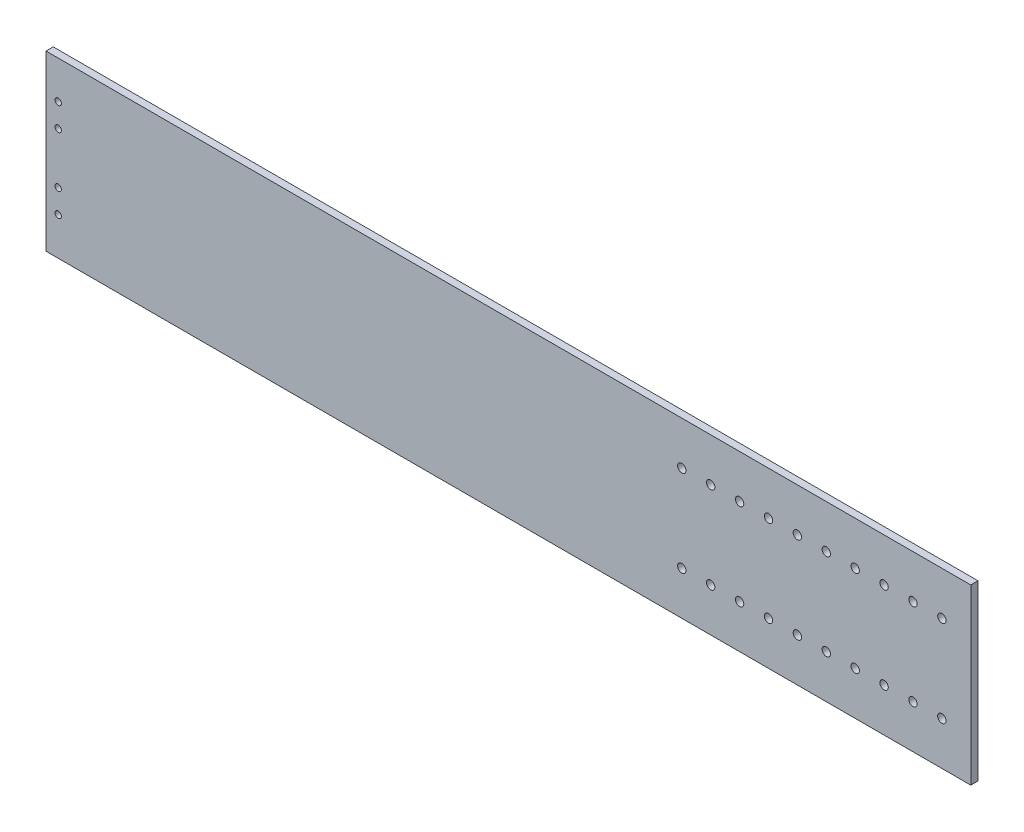
from build123d import *

# Parameters (mm, degrees)
SKETCH1_W             = 406.4
SKETCH1_H             = 76.2
BASIC_PLANK_DEPTH     = 3.175
SKETCH5_R             = 1.397
BRACKET_HOLES_DEPTH   = 4.175
SKETCH6_R             = 1.8415
PLACEMENT_HOLES_DEPTH = 4.175


with BuildPart() as part:
    # Sketch1 → basic_plank (new body)
    with BuildSketch(Plane.XY):
        with Locations((203.2, 38.1)):
            Rectangle(SKETCH1_W, SKETCH1_H)
    extrude(amount=BASIC_PLANK_DEPTH)

    # Sketch5 → bracket holes (cut, through all)
    with BuildSketch(Plane.XY.offset(3.175)):
        with Locations((5.3594, 59.5884)):
            Circle(SKETCH5_R)
        with Locations((5.3594, 16.6116)):
            Circle(SKETCH5_R)
        with Locations((5.3594, 49.3014)):
            Circle(SKETCH5_R)
        with Locations((5.3594, 26.8986)):
            Circle(SKETCH5_R)
    extrude(amount=-BRACKET_HOLES_DEPTH, mode=Mode.SUBTRACT)

    # Sketch6 → placement holes (cut, through all)
    with BuildSketch(Plane.XY.offset(3.175)):
        with Locations((279.4, 57.15)):
            Circle(SKETCH6_R)
        with Locations((292.1, 57.15)):
            Circle(SKETCH6_R)
        with Locations((304.8, 57.15)):
            Circle(SKETCH6_R)
        with Locations((317.5, 57.15)):
            Circle(SKETCH6_R)
        with Locations((330.2, 57.15)):
            Circle(SKETCH6_R)
        with Locations((342.9, 57.15)):
            Circle(SKETCH6_R)
        with Locations((355.6, 57.15)):
            Circle(SKETCH6_R)
        with Locations((368.3, 57.15)):
            Circle(SKETCH6_R)
        with Locations((381, 57.15)):
            Circle(SKETCH6_R)
        with Locations((393.7, 57.15)):
            Circle(SKETCH6_R)
        with Locations((393.7, 19.05)):
            Circle(SKETCH6_R)
        with Locations((381, 19.05)):
            Circle(SKETCH6_R)
        with Locations((368.3, 19.05)):
            Circle(SKETCH6_R)
        with Locations((355.6, 19.05)):
            Circle(SKETCH6_R)
        with Locations((342.9, 19.05)):
            Circle(SKETCH6_R)
        with Locations((330.2, 19.05)):
            Circle(SKETCH6_R)
        with Locations((317.5, 19.05)):
            Circle(SKETCH6_R)
        with Locations((304.8, 19.05)):
            Circle(SKETCH6_R)
        with Locations((292.1, 19.05)):
            Circle(SKETCH6_R)
        with Locations((279.4, 19.05)):
            Circle(SKETCH6_R)
    extrude(amount=-PLACEMENT_HOLES_DEPTH, mode=Mode.SUBTRACT)


solid = part.part
